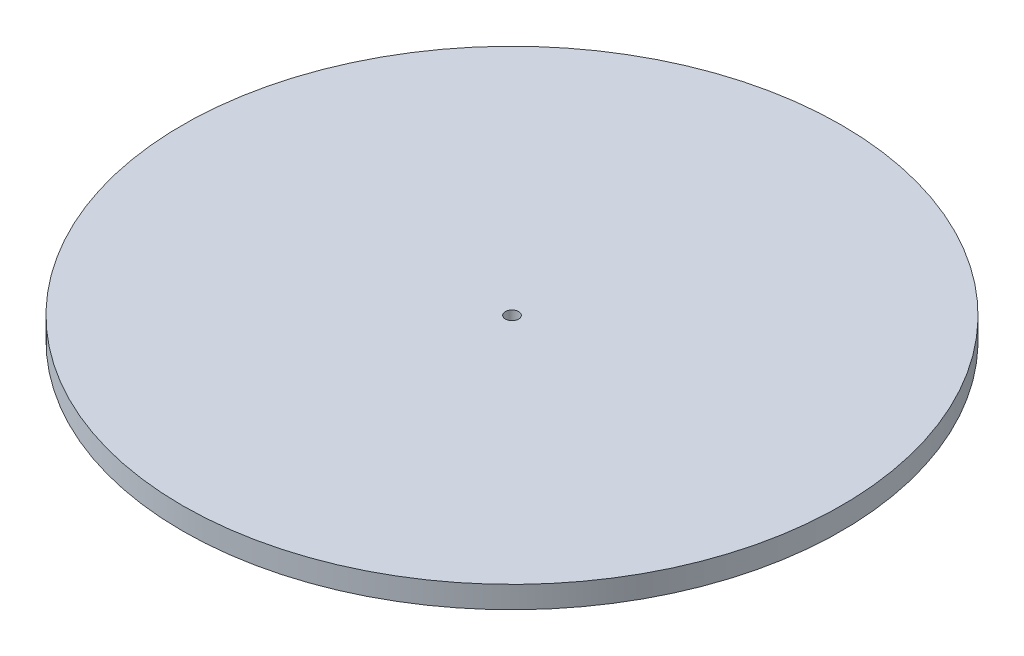
from build123d import *

# Parameters (mm, degrees)
SKETCH1_R           = 150
SKETCH1_R_2         = 3
BOSS_EXTRUDE1_DEPTH = 10


with BuildPart() as part:
    # Sketch1 → Boss-Extrude1 (new body)
    with BuildSketch(Plane(origin=(0, 0, 0), x_dir=(1, 0, 0), z_dir=(0, 1, 0))):
        Circle(SKETCH1_R)
        Circle(SKETCH1_R_2, mode=Mode.SUBTRACT)
    extrude(amount=BOSS_EXTRUDE1_DEPTH)


solid = part.part
